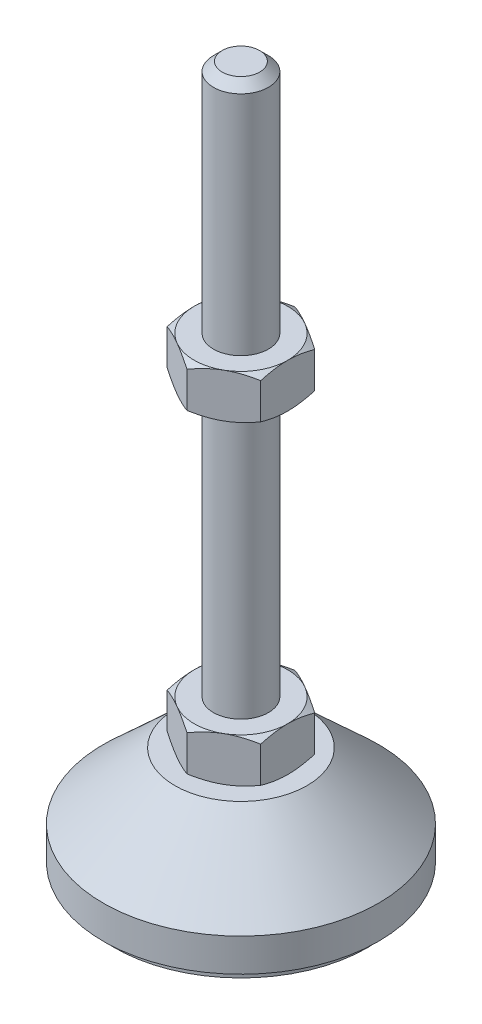
from build123d import *

# Parameters (mm, degrees)
EXTRUDE_1_DEPTH = 8
EXTRUDE_2_DEPTH = 8


with BuildPart() as part:
    # Эскиз1 → Повернуть1 (revolve)
    with BuildSketch(Plane.XY, mode=Mode.PRIVATE) as revolve_1_sk:
        Polygon((0, 0), (-23, 0), (-23, 2), (-25, 2), (-25, 8), (-12, 20), (-5, 20), (-5, 28), (-5, 126.4), (-3.4, 128), (0, 128), align=None)
    revolve(revolve_1_sk.sketch.rotate(Axis((0, 0, 0), (0, 1, 0)), 180), axis=Axis((0, 0, 0), (0, 1, 0)))  # turned: the seam where the file's is

    # Эскиз2 → Бобышка-Вытянуть1 (add)
    with BuildSketch(Plane(origin=(0, 20, 0), x_dir=(1, 0, 0), z_dir=(0, 1, 0))):
        Polygon((0, 9.814954576), (-8.5, 4.907477288), (-8.5, -4.907477288), (0, -9.814954576), (8.5, -4.907477288), (8.5, 4.907477288), align=None)
    extrude(amount=EXTRUDE_1_DEPTH)

    # Эскиз3 → Бобышка-Вытянуть2 (add)
    with BuildSketch(Plane(origin=(0, 77.2, 0), x_dir=(1, 0, 0), z_dir=(0, 1, 0))):
        Polygon((8.5, 4.907477288), (0, 9.814954576), (-8.5, 4.907477288), (-8.5, -4.907477288), (0, -9.814954576), (8.5, -4.907477288), align=None)
    extrude(amount=EXTRUDE_2_DEPTH)

    # Эскиз4 → Вырез-Повернуть2 (revolve, cut)
    with BuildSketch(Plane.XY, mode=Mode.PRIVATE) as cut_revolve_2_sk:
        Polygon((-15.42820323, 85.2), (-8.5, 85.2), (-15.42820323, 81.2), align=None)
        Polygon((-15.42820323, 77.2), (-15.42820323, 81.2), (-8.5, 77.2), align=None)
        Polygon((-15.42820323, 28), (-15.42820323, 24), (-8.5, 28), align=None)
        Polygon((-15.42820323, 24), (-15.42820323, 20), (-8.5, 20), align=None)
    revolve(cut_revolve_2_sk.sketch.rotate(Axis((0, 128, 0), (0, -1, 0)), 180), axis=Axis((0, 128, 0), (0, -1, 0)), mode=Mode.SUBTRACT)  # turned: the seam where the file's is


solid = part.part
